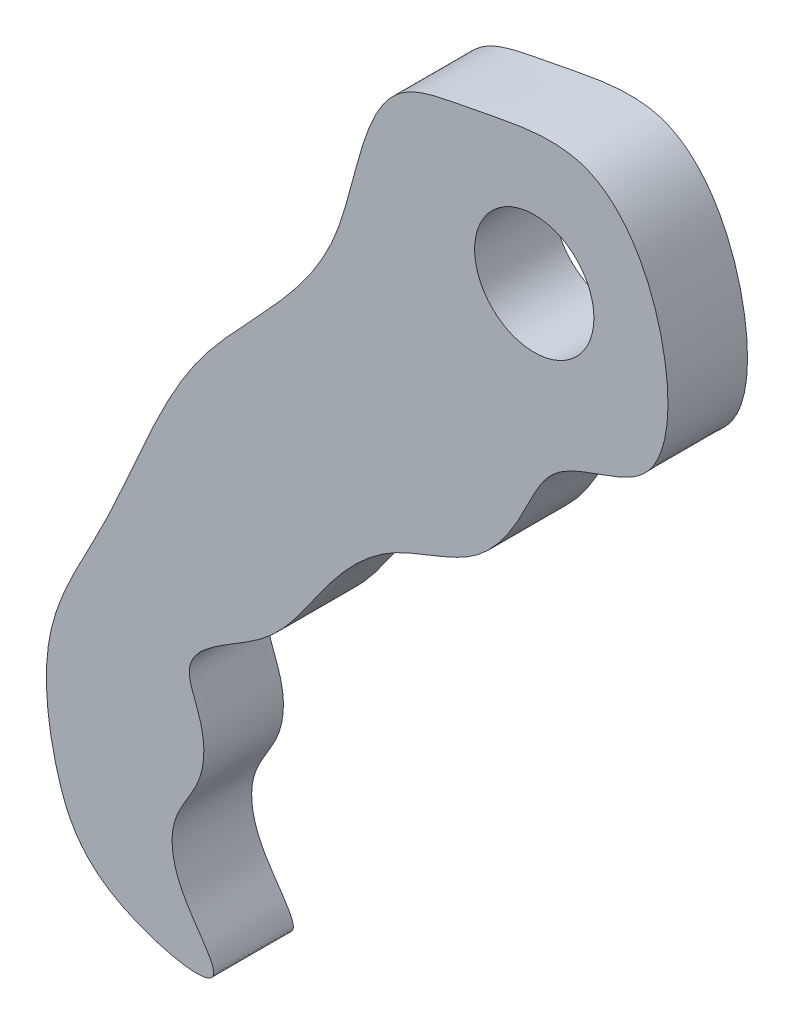
from build123d import *

# Parameters (mm, degrees)
SKETCH1_R           = 2.38125
BOSS_EXTRUDE1_DEPTH = 3.175


with BuildPart() as part:
    # Sketch1 → Boss-Extrude1 (new body)
    with BuildSketch(Plane.XY):
        with BuildLine():
            add(Edge.make_bspline(
                [(243.379099576, 197.056803539), (243.273767243, 196.380230238), (238.48231818, 197.440811155), (236.878297925, 201.052642192), (236.364264799, 205.874793844), (239.690035363, 211.211009056), (242.060834704, 218.617976605), (249.033898084, 223.525034573), (249.293181904, 231.416122496), (254.255634963, 232.164361696), (259.020617957, 233.410244688), (261.864774852, 227.942592225), (261.400186865, 222.206225967), (256.8542999, 221.882324013), (255.672295974, 218.82670566), (253.830317651, 216.248187105), (250.236400576, 215.500942686), (247.560529564, 212.510429103), (245.811030732, 209.37716596), (241.728232672, 207.815633377), (243.083745802, 205.35287159), (243.001710769, 203.403584428), (241.529713627, 201.62970516), (241.78131291, 199.264613846), (243.445133037, 197.480951335), (243.379099576, 197.056803539)],
                knots=[0, 0, 0, 0, 0.042450071, 0.084450706, 0.131899967, 0.185560177, 0.278186288, 0.370886872, 0.444065634, 0.471111888, 0.520415609, 0.583030286, 0.631486922, 0.67177894, 0.698064998, 0.729106004, 0.768158638, 0.806911928, 0.849726211, 0.888523994, 0.90498188, 0.927291753, 0.947233338, 0.9733878, 1, 1, 1, 1], degree=3))
        make_face()
        with Locations((256.174942949, 227.325591656)):
            Circle(SKETCH1_R, mode=Mode.SUBTRACT)
    extrude(amount=BOSS_EXTRUDE1_DEPTH)


solid = part.part
